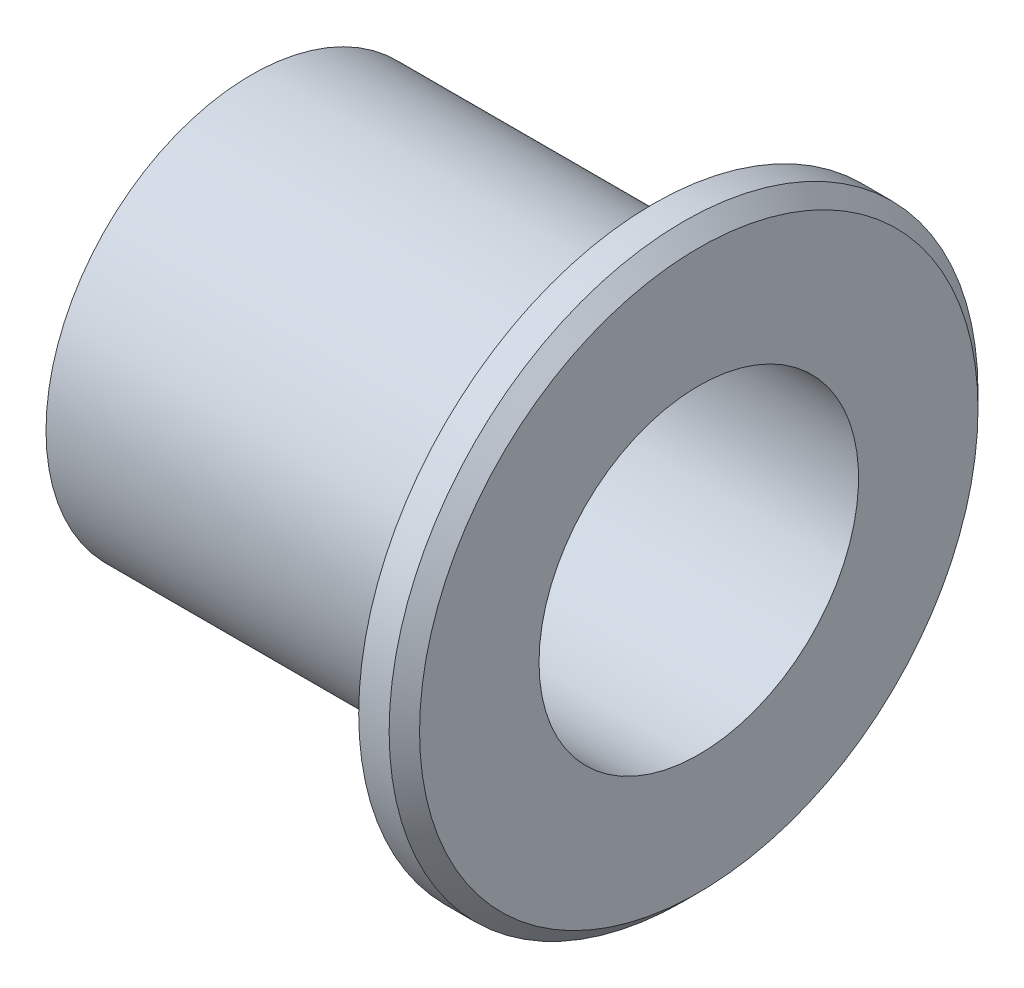
from build123d import *

# Parameters (mm, degrees)
CUT_EXTRUDE_1_DEPTH = 30.4
CHAMFER_1_SIZE      = 1
SKETCH_3_R          = 1.25
CUT_EXTRUDE_2_DEPTH = 30.4


with BuildPart() as part:
    # 草图1 → 旋转1 (revolve)
    with BuildSketch(Plane.XY):
        Polygon((29.4, 19.35), (29.4, 10.5), (8, 10.5), (8, 0), (0, 0), (0, 13.5), (24.5, 13.5), (24.5, 12.5), (26.4, 12.5), (26.4, 19.35), align=None)
    revolve(axis=Axis((0, 0, 0), (1, 0, 0)))

    # 草图2 → 切除-拉伸1 (cut, through all)
    with BuildSketch(Plane(origin=(29.4, 0, 0), x_dir=(0, 0, -1), z_dir=(1, 0, 0))):
        Polygon((-2.309401077, 4), (-4.618802154, 0), (-2.309401077, -4), (2.309401077, -4), (4.618802154, 0), (2.309401077, 4), align=None)
    extrude(amount=-CUT_EXTRUDE_1_DEPTH, mode=Mode.SUBTRACT)

    # 倒角1
    chamfer_1_edges = [part.edges().sort_by_distance(p)[0] for p in [
        (29.4, -19.35, 0),
    ]]
    chamfer(chamfer_1_edges, length=CHAMFER_1_SIZE)

    # 草图3 → 切除-拉伸2 (cut, through all)
    with BuildSketch(Plane(origin=(29.4, 0, 0), x_dir=(0, 0, -1), z_dir=(1, 0, 0))):
        with Locations((0, 7)):
            Circle(SKETCH_3_R)
        with Locations((0, -7)):
            Circle(SKETCH_3_R)
    extrude(amount=-CUT_EXTRUDE_2_DEPTH, mode=Mode.SUBTRACT)


solid = part.part
